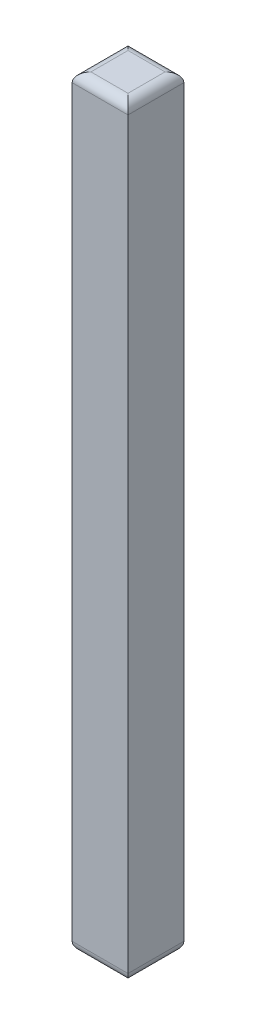
from build123d import *

# Parameters (mm, degrees)
SKETCH1_W           = 3.0226
SKETCH1_H           = 3.0226
BOSS_EXTRUDE1_DEPTH = 41.275
FILLET1_R           = 0.508


with BuildPart() as part:
    # Sketch1 → Boss-Extrude1 (new body)
    with BuildSketch(Plane(origin=(0, 0, 0), x_dir=(1, 0, 0), z_dir=(0, 1, 0))):
        with Locations((1.5113, 1.5113)):
            Rectangle(SKETCH1_W, SKETCH1_H)
    extrude(amount=BOSS_EXTRUDE1_DEPTH)

    # Fillet1
    fillet1_edges = [part.edges().sort_by_distance(p)[0] for p in [
        (3.0226, 41.275, -1.5113),
        (1.5113, 41.275, -3.0226),
        (0, 41.275, -1.5113),
        (1.5113, 0, -3.0226),
        (3.0226, 0, -1.5113),
        (1.5113, 0, 0),
        (0, 0, -1.5113),
        (1.5113, 41.275, 0),
    ]]
    fillet(fillet1_edges, radius=FILLET1_R)


solid = part.part
